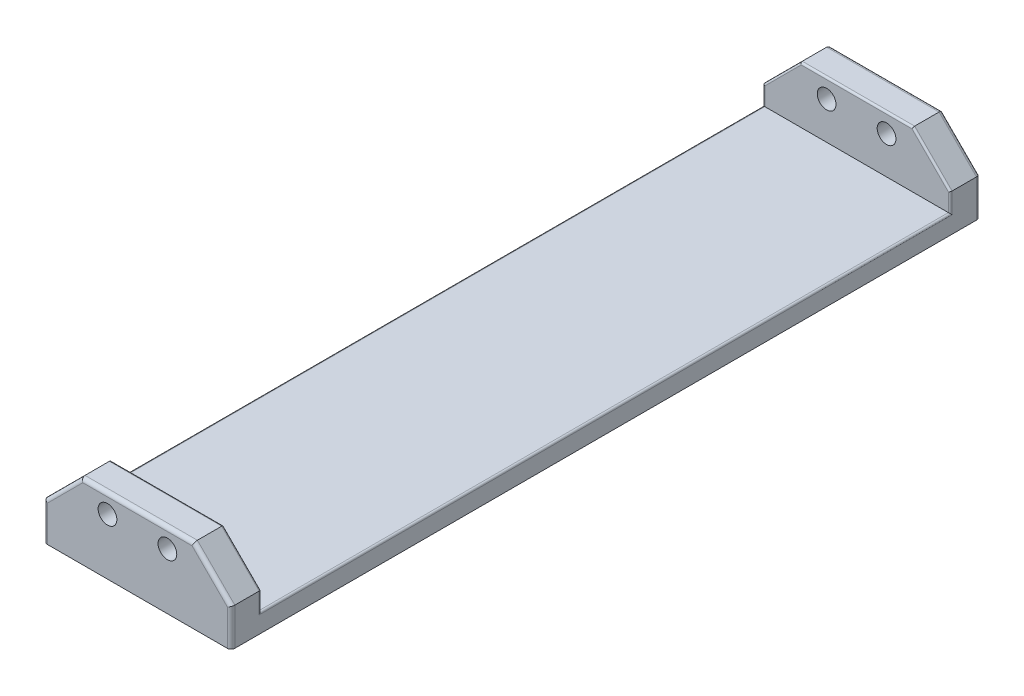
from build123d import *

# Parameters (mm, degrees)
SKETCH1_W           = 500
SKETCH1_H           = 200
BOSS_EXTRUDE1_DEPTH = 2000
SKETCH3_W           = 1840
SKETCH3_H           = 150
CUT_EXTRUDE1_DEPTH  = 1000
CUT_EXTRUDE2_DEPTH  = 2001
SKETCH4_R           = 25
CUT_EXTRUDE3_DEPTH  = 2001
FILLET1_R           = 10
FILLET2_R           = 10
FILLET4_R           = 5


with BuildPart() as part:
    # Sketch1 → Boss-Extrude1 (new body)
    with BuildSketch(Plane.XY):
        Rectangle(SKETCH1_W, SKETCH1_H)
    extrude(amount=BOSS_EXTRUDE1_DEPTH)

    # Sketch3 → Cut-Extrude1 (cut)
    with BuildSketch(Plane.ZY.offset(250)):
        with Locations((1000, 25)):
            Rectangle(SKETCH3_W, SKETCH3_H)
    extrude(amount=-CUT_EXTRUDE1_DEPTH, mode=Mode.SUBTRACT)

    # Sketch2 → Cut-Extrude2 (cut, through all)
    with BuildSketch(Plane.XY.offset(2000)):
        Polygon((-250, 0), (-150, 100), (-250, 100), align=None)
        Polygon((250, 0), (150, 100), (250, 100), align=None)
    extrude(amount=-CUT_EXTRUDE2_DEPTH, mode=Mode.SUBTRACT)

    # Sketch4 → Cut-Extrude3 (cut, through all)
    with BuildSketch(Plane.XY.offset(2000)):
        with Locations((-80, 50)):
            Circle(SKETCH4_R)
        with Locations((80, 50)):
            Circle(SKETCH4_R)
    extrude(amount=-CUT_EXTRUDE3_DEPTH, mode=Mode.SUBTRACT)

    # Fillet1
    fillet1_edges = [part.edges().sort_by_distance(p)[0] for p in [
        (-250, -50, 2000),
        (250, -50, 2000),
        (-200, 50, 2000),
        (0, 100, 2000),
        (200, 50, 2000),
    ]]
    fillet(fillet1_edges, radius=FILLET1_R)

    # Fillet2
    fillet2_edges = [part.edges().sort_by_distance(p)[0] for p in [
        (-250, -50, 0),
        (-200, 50, 0),
        (0, 100, 0),
        (250, -50, 0),
        (200, 50, 0),
    ]]
    fillet(fillet2_edges, radius=FILLET2_R)

    # Fillet4
    fillet4_edges = [part.edges().sort_by_distance(p)[0] for p in [
        (250, -25, 1920),
        (250, -50, 1000),
        (-250, -50, 1000),
        (-250, -25, 1920),
        (-200, 50, 1920),
        (-250, -25, 80),
        (-200, 50, 80),
        (0, 100, 1920),
        (200, 50, 1920),
        (0, 100, 80),
        (250, -25, 80),
        (200, 50, 80),
    ]]
    fillet(fillet4_edges, radius=FILLET4_R)


solid = part.part
